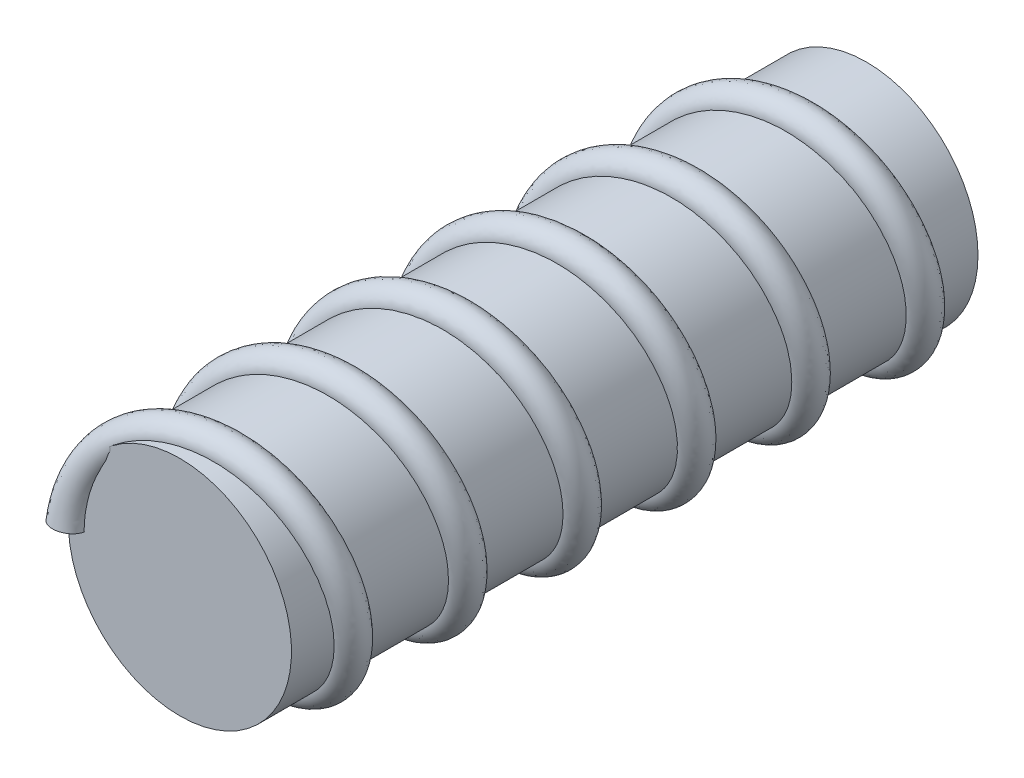
from build123d import *

# Parameters (mm, degrees)
SKETCH2_R           = 21
BOSS_EXTRUDE2_DEPTH = 129.239907


with BuildPart() as part:
    # Sketch2 → Boss-Extrude2 (new body)
    with BuildSketch(Plane.XY):
        Circle(SKETCH2_R)
    extrude(amount=BOSS_EXTRUDE2_DEPTH)


solid = part.part
